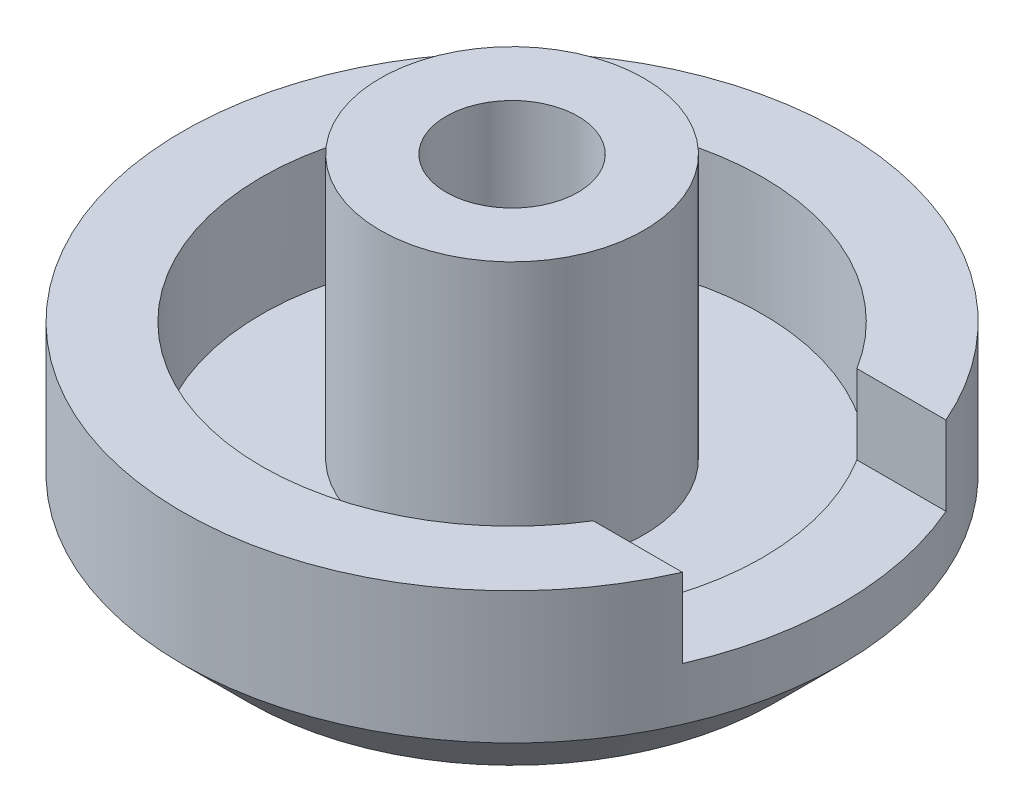
from build123d import *

# Parameters (mm, degrees)
SKETCH1_R           = 5
BOSS_EXTRUDE1_DEPTH = 3
SKETCH3_R           = 3.8
CUT_EXTRUDE1_DEPTH  = 1.8
SKETCH4_R           = 2
BOSS_EXTRUDE2_DEPTH = 4
SKETCH5_R           = 1
CUT_EXTRUDE2_DEPTH  = 4
SKETCH6_W           = 4
SKETCH6_H           = 4
CUT_EXTRUDE3_DEPTH  = 1.2
CHAMFER1_SIZE       = 1


with BuildPart() as part:
    # Sketch1 → Boss-Extrude1 (new body)
    with BuildSketch(Plane(origin=(0, 0, 0), x_dir=(1, 0, 0), z_dir=(0, 1, 0))):
        Circle(SKETCH1_R)
    extrude(amount=BOSS_EXTRUDE1_DEPTH)

    # Sketch3 → Cut-Extrude1 (cut)
    with BuildSketch(Plane(origin=(0, 3, 0), x_dir=(1, 0, 0), z_dir=(0, 1, 0))):
        Circle(SKETCH3_R)
    extrude(amount=-CUT_EXTRUDE1_DEPTH, mode=Mode.SUBTRACT)

    # Sketch4 → Boss-Extrude2 (add)
    with BuildSketch(Plane(origin=(0, 1.2, 0), x_dir=(1, 0, 0), z_dir=(0, 1, 0))):
        Circle(SKETCH4_R)
    extrude(amount=BOSS_EXTRUDE2_DEPTH)

    # Sketch5 → Cut-Extrude2 (cut)
    with BuildSketch(Plane(origin=(0, 5.2, 0), x_dir=(1, 0, 0), z_dir=(0, 1, 0))):
        Circle(SKETCH5_R)
    extrude(amount=-CUT_EXTRUDE2_DEPTH, mode=Mode.SUBTRACT)

    # Sketch6 → Cut-Extrude3 (cut)
    with BuildSketch(Plane(origin=(0, 3, 0), x_dir=(1, 0, 0), z_dir=(0, 1, 0))):
        with Locations((4, 0)):
            Rectangle(SKETCH6_W, SKETCH6_H)
    extrude(amount=-CUT_EXTRUDE3_DEPTH, mode=Mode.SUBTRACT)

    # Chamfer1
    chamfer1_edges = [part.edges().sort_by_distance(p)[0] for p in [
        (-5, 0, 0),
    ]]
    chamfer(chamfer1_edges, length=CHAMFER1_SIZE)


solid = part.part
